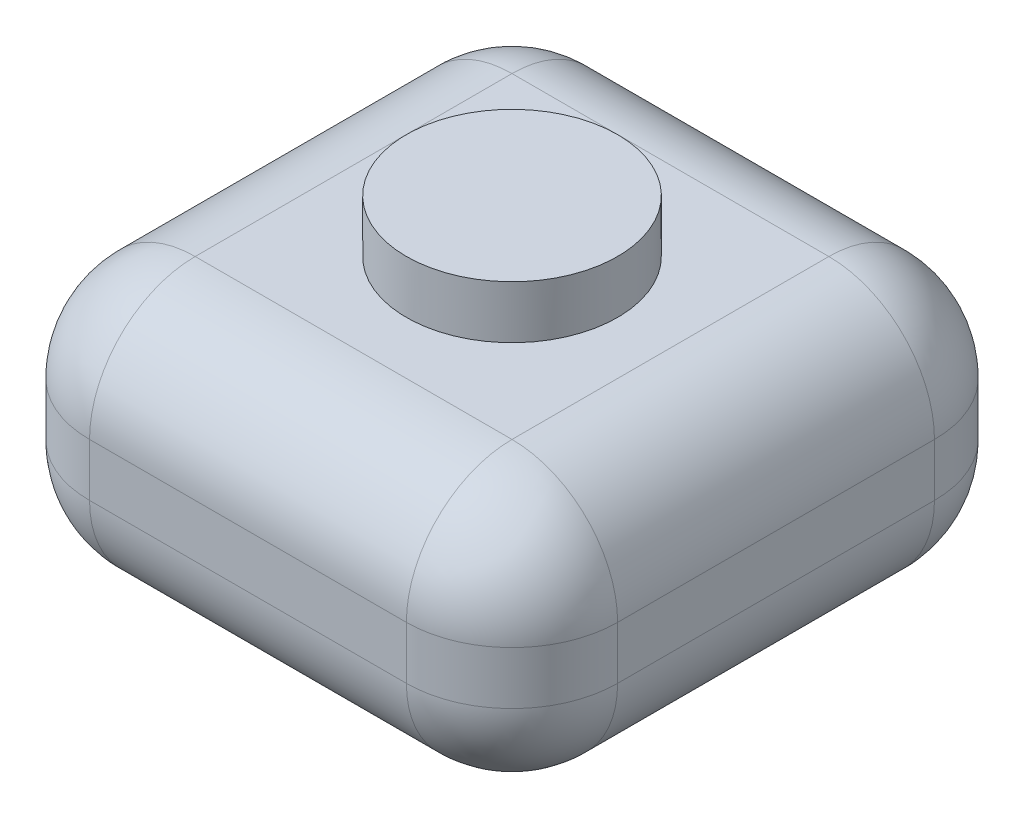
from build123d import *

# Parameters (mm, degrees)
SKETCH_1_W      = 10
SKETCH_1_H      = 10
EXTRUDE_1_DEPTH = 5
FILLET_2_R      = 2
SKETCH_2_R      = 2
EXTRUDE_2_DEPTH = 1


with BuildPart() as part:
    # 草图1 → 凸台-拉伸1 (new body)
    with BuildSketch(Plane(origin=(0, 0, 0), x_dir=(1, 0, 0), z_dir=(0, 1, 0))):
        Rectangle(SKETCH_1_W, SKETCH_1_H)
    extrude(amount=EXTRUDE_1_DEPTH)

    # 圆角2
    fillet_2_edges = [part.edges().sort_by_distance(p)[0] for p in [
        (5, 5, 0),
        (0, 5, 5),
        (-5, 5, 0),
        (0, 0, 5),
        (5, 0, 0),
        (0, 0, -5),
        (-5, 0, 0),
        (-5, 2.5, 5),
        (5, 2.5, 5),
        (5, 2.5, -5),
        (-5, 2.5, -5),
        (0, 5, -5),
    ]]
    fillet(fillet_2_edges, radius=FILLET_2_R)

    # 草图2 → 凸台-拉伸2 (add)
    with BuildSketch(Plane(origin=(0, 5, 0), x_dir=(1, 0, 0), z_dir=(0, 1, 0))):
        Circle(SKETCH_2_R)
    extrude(amount=EXTRUDE_2_DEPTH)


solid = part.part
